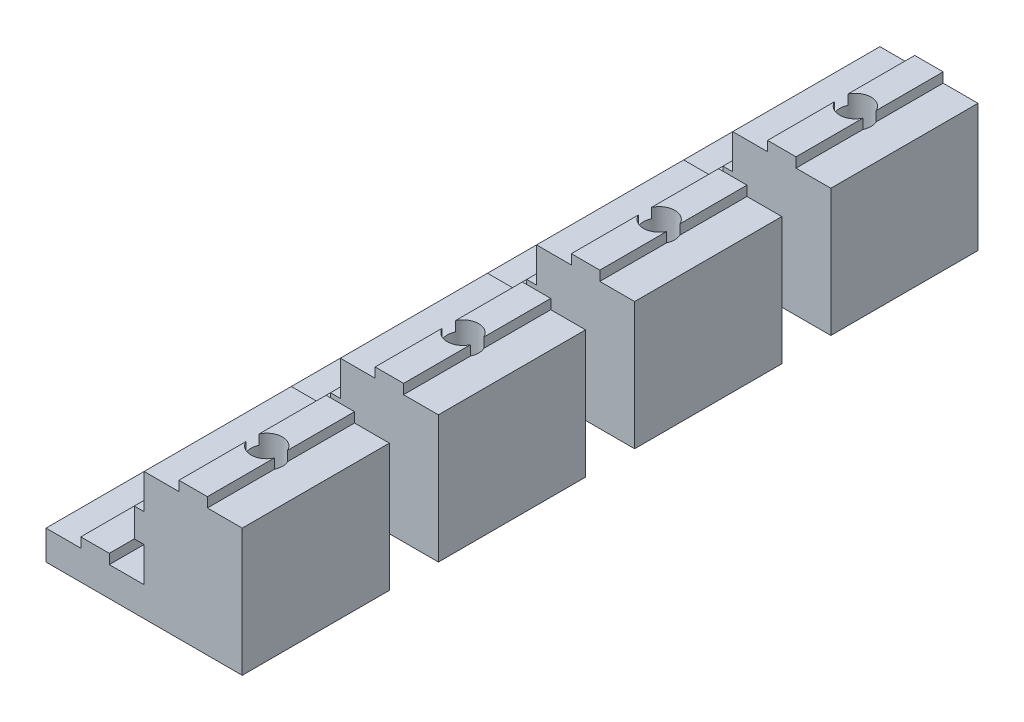
from build123d import *

# Parameters (mm, degrees)
MAIN_DEPTH         = 15
ESQUISSE2_R        = 1.6
TOPHOLE_DEPTH      = 29.653097564
SKETCH1_R          = 4.25
CUT_EXTRUDE1_DEPTH = 10
LPATTERN1_COUNT    = 4
LPATTERN1_PITCH    = 20


with BuildPart() as part:
    # Esquisse1 → Main (new body)
    with BuildSketch(Plane.XY):
        Polygon((-20, 0), (-20, 3), (-16.45, 3), (-16.45, 4), (-13.55, 4), (-13.55, 3), (-10, 3), (-10, 6.55), (-11, 6.55), (-11, 9.45), (-10, 9.45), (-10, 13), (-6.45, 13), (-6.45, 14), (-3.55, 14), (-3.55, 13), (0, 13), (0, 0), align=None)
    extrude(amount=MAIN_DEPTH)

    # Esquisse2 → TopHole (cut, through all)
    with BuildSketch(Plane(origin=(0, 14, 0), x_dir=(1, 0, 0), z_dir=(0, 1, 0))):
        with Locations((-5, -7.5)):
            Circle(ESQUISSE2_R)
        with Locations((-15, -7.5)):
            Circle(ESQUISSE2_R)
    extrude(amount=-TOPHOLE_DEPTH, mode=Mode.SUBTRACT)

    # Sketch1 → Cut-Extrude1 (cut)
    with BuildSketch(Plane(origin=(0, 0, 0), x_dir=(-1, 0, 0), z_dir=(0, -1, 0))):
        with Locations((5, -7.5)):
            Circle(SKETCH1_R)
    extrude(amount=-CUT_EXTRUDE1_DEPTH, mode=Mode.SUBTRACT)


with BuildPart() as lpattern1_1:
    # LPattern1: pattern copy
    add(part.part.moved(Location(Vector(0, 0, 1) * (1 * LPATTERN1_PITCH))))


with BuildPart() as lpattern1_2:
    # LPattern1: pattern copy
    add(part.part.moved(Location(Vector(0, 0, 1) * (2 * LPATTERN1_PITCH))))


with BuildPart() as lpattern1_3:
    # LPattern1: pattern copy
    add(part.part.moved(Location(Vector(0, 0, 1) * (3 * LPATTERN1_PITCH))))


solid = Compound([part.part, lpattern1_1.part, lpattern1_2.part, lpattern1_3.part])
